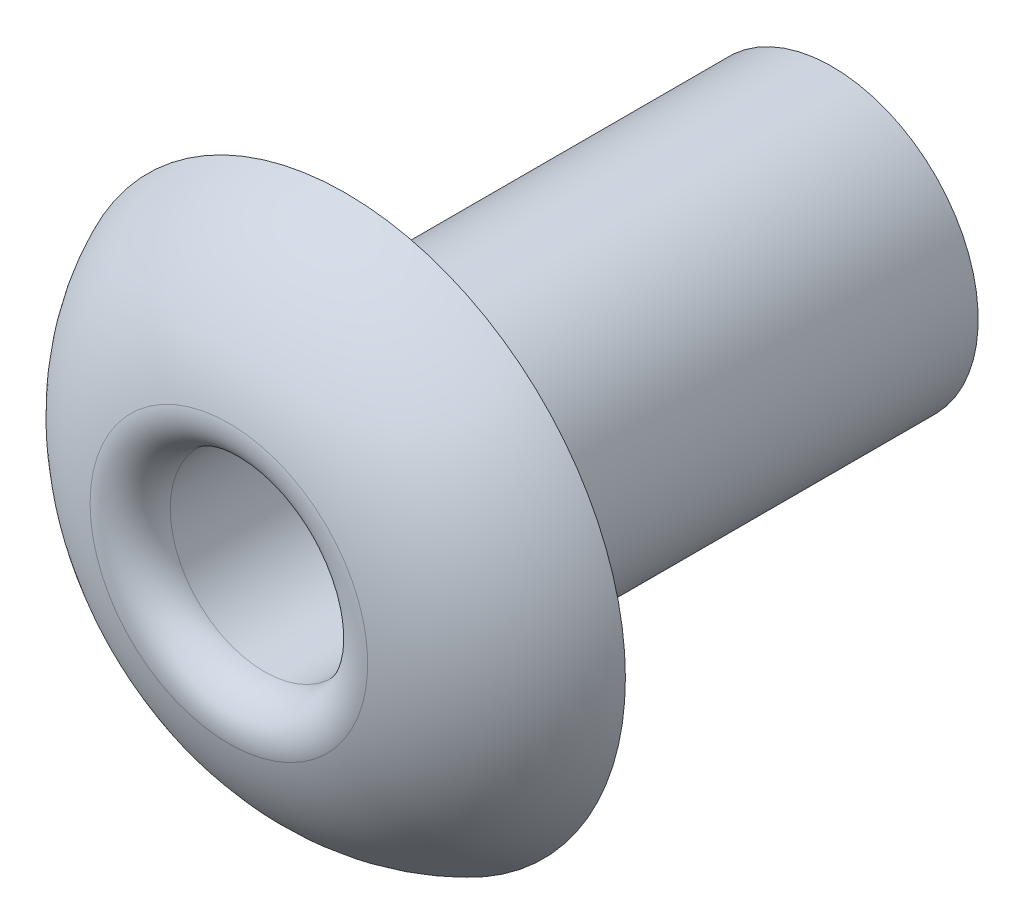
from build123d import *

# Parameters (mm, degrees)
FILLET_527_R = 0.3


with BuildPart() as part:
    # 草图1 → 旋转1 (revolve)
    with BuildSketch(Plane(origin=(0, 0, 0), x_dir=(0, 0, -1), z_dir=(1, 0, 0))):
        with BuildLine():
            Line((0, 1.2), (0, 2.3))
            ThreePointArc((0, 2.3), (-0.727705087, 1.686814811), (-1, 0.775))
            Line((-1, 0.775), (4, 0.775))
            Line((4, 0.775), (4, 1.2))
            Line((4, 1.2), (0, 1.2))
        make_face()
    revolve(axis=Axis((0, 0, -4), (0, 0, 1)))

    # Fillet 527
    fillet_527_edges = [part.edges().sort_by_distance(p)[0] for p in [
        (0, -0.775, 1),
    ]]
    fillet(fillet_527_edges, radius=FILLET_527_R)


solid = part.part
